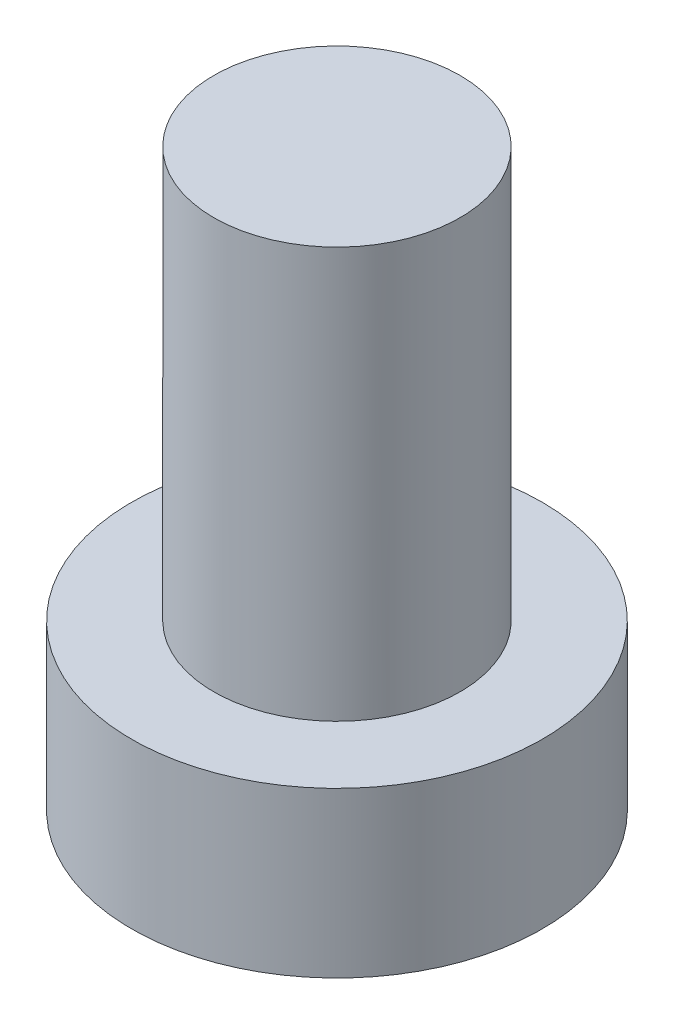
from build123d import *

# Parameters (mm, degrees)
SKETCH1_R      = 3
EXTRUDE1_DEPTH = 10
SKETCH2_R      = 5
EXTRUDE2_DEPTH = 4


with BuildPart() as part:
    # Sketch1 → Extrude1 (new body)
    with BuildSketch(Plane(origin=(0, 0, 0), x_dir=(1, 0, 0), z_dir=(0, 1, 0))):
        with Locations(Location((0, 0, 0), (0, 0, 270))):  # turned: the seam where the file's is
            Circle(SKETCH1_R)
    extrude(amount=EXTRUDE1_DEPTH)

    # Sketch2 → Extrude2 (add)
    with BuildSketch(Plane.XZ):
        with Locations(Location((0, 0, 0), (0, 0, 270))):  # turned: the seam where the file's is
            Circle(SKETCH2_R)
    extrude(amount=EXTRUDE2_DEPTH)


solid = part.part
